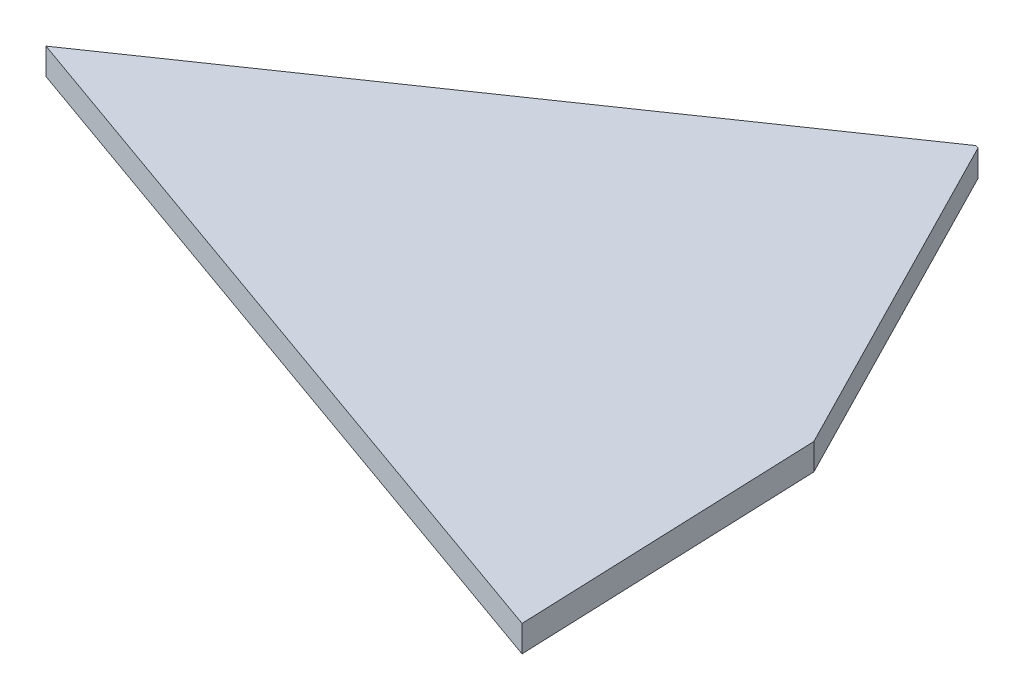
from build123d import *

# Parameters (mm, degrees)
BOSS_EXTRU_1_DEPTH = 2


with BuildPart() as part:
    # Esquisse1 → Boss.-Extru.1 (new body)
    with BuildSketch(Plane(origin=(0, 0, 0), x_dir=(1, 0, 0), z_dir=(0, 1, 0))):
        Polygon((41.760983354, 28.704197748), (0, 0), (55.916304476, -19.84742116), (55.030752678, 3.146553991), (41.99255262, 28.622002531), align=None)
    extrude(amount=BOSS_EXTRU_1_DEPTH)


solid = part.part
